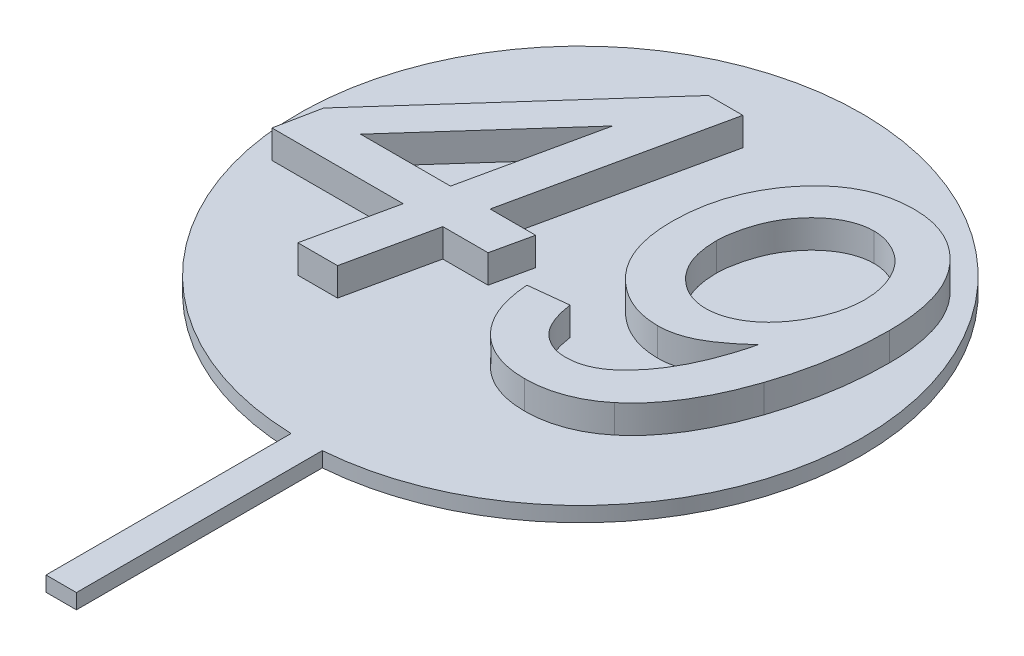
from build123d import *

# Parameters (mm, degrees)
SKETCH_1_R      = 30
EXTRUDE_1_DEPTH = 1.6
EXTRUDE_2_DEPTH = 3
SKETCH_3_W      = 3.244311069
SKETCH_3_H      = 35.273993815
EXTRUDE_5_DEPTH = 1.6


with BuildPart() as part:
    # Эскиз1 → Бобышка-Вытянуть1 (new body)
    with BuildSketch(Plane(origin=(0, 0, 0), x_dir=(1, 0, 0), z_dir=(0, 1, 0))):
        Circle(SKETCH_1_R)
    extrude(amount=EXTRUDE_1_DEPTH)

    # Эскиз2 → Бобышка-Вытянуть2 (add)
    with BuildSketch(Plane(origin=(0, 1.6, 0), x_dir=(1, 0, 0), z_dir=(0, 1, 0))):
        Polygon((-15.112940101, -15.010744766), (-13.103354207, -5.79113923), (-27.098427297, -5.79113923), (-26.176466744, -1.195742096), (-6.815295119, 20.484736546), (-3.156264172, 20.484736546), (-7.974948628, -1.642316739), (-3.127452905, -1.642316739), (-4.049413459, -5.79113923), (-8.875300731, -5.79113923), (-10.884886625, -15.010744766), align=None)
        Polygon((-12.203002104, -1.642316739), (-9.112993686, 12.561638039), (-21.797154114, -1.642316739), align=None, mode=Mode.SUBTRACT)
        with BuildLine():
            Line((1.021369586, -6.713099784), (5.155786443, -6.252119507))
            add(Edge.make_bspline(
                [(5.155786443, -6.252119507), (5.192135281, -6.473381577), (5.262387165, -6.901017726), (5.397879979, -7.515231953), (5.562416953, -8.078982569), (5.75783084, -8.594252788), (5.978056496, -9.060074627), (6.225780557, -9.477912909), (6.498384414, -9.845044122), (6.888403904, -10.266320667), (7.442457962, -10.681510063), (8.162107094, -11.060328313), (8.950693699, -11.283404951), (9.495307412, -11.309570842), (9.772792028, -11.322902552)],
                knots=[0, 0, 0, 0, 0.000672606, 0.001299954, 0.00188569, 0.002432819, 0.002951522, 0.003429575, 0.003887676, 0.004320864, 0.005147809, 0.005949945, 0.006750366, 0.007581816, 0.007581816, 0.007581816, 0.007581816], degree=3))
            add(Edge.make_bspline(
                [(9.772792028, -11.322902552), (9.974836791, -11.315289739), (10.378983376, -11.300061965), (10.979375815, -11.198014835), (11.565207937, -11.022197171), (12.140680484, -10.782461737), (12.704801504, -10.469434648), (13.257512824, -10.085992109), (13.800962323, -9.638904949), (14.138144983, -9.299567127), (14.310566627, -9.12604342)],
                knots=[0, 0, 0, 0, 0.000606108, 0.001212386, 0.001820886, 0.002437558, 0.003079094, 0.003752394, 0.004453291, 0.005186777, 0.005186777, 0.005186777, 0.005186777], degree=3))
            add(Edge.make_bspline(
                [(14.310566627, -9.12604342), (14.562332157, -8.846489735), (15.074816945, -8.277440386), (15.771928843, -7.338032377), (16.413643396, -6.306492), (17.009949904, -5.193403292), (17.552241758, -3.989577112), (18.036311249, -2.697590667), (18.489551109, -1.323270245), (18.731729262, -0.366685376), (18.855544044, 0.122373383)],
                knots=[0, 0, 0, 0, 0.001128178, 0.002296479, 0.003503568, 0.004769995, 0.006082035, 0.007461238, 0.008907642, 0.010420662, 0.010420662, 0.010420662, 0.010420662], degree=3))
            add(Edge.make_bspline(
                [(18.855544044, 0.122373383), (18.515554142, -0.181681505), (17.868313732, -0.760512257), (16.895223997, -1.523524974), (15.986257834, -2.159743633), (15.121792782, -2.661558355), (14.274538335, -3.030078632), (13.434324295, -3.290513005), (12.583841099, -3.459331039), (12.011241698, -3.477265014), (11.724755387, -3.486237846)],
                knots=[0, 0, 0, 0, 0.001368042, 0.002604349, 0.003707227, 0.004694433, 0.005597662, 0.0064725, 0.007329998, 0.008188615, 0.008188615, 0.008188615, 0.008188615], degree=3))
            add(Edge.make_bspline(
                [(11.724755387, -3.486237846), (11.467545037, -3.478838371), (10.95835582, -3.464189922), (10.202997804, -3.361403617), (9.470361257, -3.188438097), (8.755779823, -2.949020303), (8.065155466, -2.63719131), (7.391074846, -2.26158419), (6.74101139, -1.813836573), (6.334287268, -1.470552033), (6.128166715, -1.296581532)],
                knots=[0, 0, 0, 0, 0.000771542, 0.001527392, 0.002282143, 0.003026964, 0.003784631, 0.004552094, 0.00533928, 0.006148115, 0.006148115, 0.006148115, 0.006148115], degree=3))
            add(Edge.make_bspline(
                [(6.128166715, -1.296581532), (5.866741871, -1.053430833), (5.344675784, -0.567858261), (4.68598861, 0.277826316), (4.120100969, 1.190125333), (3.651772278, 2.178943205), (3.306695947, 3.251277107), (3.042972026, 4.394926248), (2.892902816, 5.618933407), (2.874665369, 6.460451788), (2.865290693, 6.893021198)],
                knots=[0, 0, 0, 0, 0.001069612, 0.002136018, 0.003203397, 0.004286026, 0.00540895, 0.006576162, 0.0078028, 0.009100287, 0.009100287, 0.009100287, 0.009100287], degree=3))
            add(Edge.make_bspline(
                [(2.865290693, 6.893021198), (2.875207181, 7.388228075), (2.89472349, 8.362828189), (3.083578082, 9.796121672), (3.373185787, 11.176809481), (3.796125522, 12.501570161), (4.330630954, 13.774732447), (4.980823191, 14.99643932), (5.751264631, 16.165307898), (6.355998775, 16.881862763), (6.66117516, 17.243468975)],
                knots=[0, 0, 0, 0, 0.001484899, 0.00292238, 0.004329457, 0.005712191, 0.007087382, 0.00846651, 0.00985891, 0.011277426, 0.011277426, 0.011277426, 0.011277426], degree=3))
            add(Edge.make_bspline(
                [(6.66117516, 17.243468975), (6.934144804, 17.537158668), (7.47161345, 18.115424437), (8.359517632, 18.87278791), (9.296948211, 19.509609385), (10.272237605, 20.044447486), (11.302446737, 20.446715103), (12.37692951, 20.736367773), (13.497965187, 20.913646613), (14.261903613, 20.934929686), (14.649099018, 20.945716823)],
                knots=[0, 0, 0, 0, 0.001202159, 0.002367012, 0.003491782, 0.004597221, 0.005696684, 0.006800948, 0.007930689, 0.009091773, 0.009091773, 0.009091773, 0.009091773], degree=3))
            add(Edge.make_bspline(
                [(14.649099018, 20.945716823), (14.997787132, 20.936379292), (15.681760043, 20.918063159), (16.687233548, 20.762950374), (17.64616698, 20.504084004), (18.560197693, 20.142451509), (19.424142306, 19.676277717), (20.242163935, 19.110195911), (21.017638488, 18.442114073), (21.740577275, 17.67553899), (22.398010202, 16.814571371), (22.978272504, 15.868653702), (23.458966364, 14.829820422), (23.856664916, 13.711476165), (24.153976582, 12.506286792), (24.379655281, 11.221838923), (24.507641015, 9.848780448), (24.523306789, 8.905267443), (24.531363702, 8.420018365)],
                knots=[0, 0, 0, 0, 0.001045625, 0.002051056, 0.003043504, 0.004019904, 0.004993138, 0.00598213, 0.006998544, 0.008058362, 0.009137391, 0.010242994, 0.011380446, 0.012565085, 0.01379843, 0.015099829, 0.016474492, 0.017930103, 0.017930103, 0.017930103, 0.017930103], degree=3))
            add(Edge.make_bspline(
                [(24.531363702, 8.420018365), (24.525664072, 7.934918015), (24.514284046, 6.966354111), (24.427262909, 5.516930729), (24.273582197, 4.073215956), (24.065445524, 2.633838437), (23.799008275, 1.199214086), (23.472015699, -0.229682915), (23.095999668, -1.657124653), (22.790400156, -2.596840611), (22.637022877, -3.068474471)],
                knots=[0, 0, 0, 0, 0.001455254, 0.002905598, 0.004354081, 0.005809709, 0.007267635, 0.008730162, 0.010206528, 0.011694097, 0.011694097, 0.011694097, 0.011694097], degree=3))
            add(Edge.make_bspline(
                [(22.637022877, -3.068474471), (22.445421429, -3.608260191), (22.072409742, -4.659120639), (21.438427503, -6.164879435), (20.744443812, -7.554296537), (20.013593824, -8.845074722), (19.218836128, -10.01903208), (18.382278177, -11.090308185), (17.500898079, -12.058312556), (16.853999376, -12.618129566), (16.536237026, -12.893116619)],
                knots=[0, 0, 0, 0, 0.00171814, 0.003344892, 0.004897513, 0.006375197, 0.00779159, 0.009146026, 0.01045087, 0.011710621, 0.011710621, 0.011710621, 0.011710621], degree=3))
            add(Edge.make_bspline(
                [(16.536237026, -12.893116619), (16.275517551, -13.099437091), (15.75979639, -13.50755326), (14.936658101, -14.031619265), (14.08857004, -14.475834427), (13.213812191, -14.833383605), (12.320192974, -15.126680855), (11.398582261, -15.328844612), (10.452772335, -15.443440865), (9.813908073, -15.462246084), (9.491882172, -15.471725043)],
                knots=[0, 0, 0, 0, 0.000996907, 0.001971952, 0.002922341, 0.00386536, 0.00480383, 0.005740556, 0.006691137, 0.007657281, 0.007657281, 0.007657281, 0.007657281], degree=3))
            add(Edge.make_bspline(
                [(9.491882172, -15.471725043), (9.198617884, -15.465062279), (8.622044237, -15.451962922), (7.778171618, -15.341349076), (6.974083778, -15.163734203), (6.214126437, -14.906579258), (5.487258858, -14.594261932), (4.811253582, -14.191925812), (4.168798029, -13.730625352), (3.581420174, -13.187339966), (3.039567521, -12.584738429), (2.563524473, -11.915474189), (2.143250657, -11.193544766), (1.789964119, -10.411188257), (1.502466787, -9.568624311), (1.27386085, -8.670395225), (1.104806925, -7.712140535), (1.049695435, -7.052260618), (1.021369586, -6.713099784)],
                knots=[0, 0, 0, 0, 0.000879481, 0.001729108, 0.002548648, 0.003345854, 0.004132776, 0.004917222, 0.005700974, 0.006501394, 0.007312503, 0.008128045, 0.008960711, 0.009814936, 0.010698742, 0.011628129, 0.012593226, 0.013613817, 0.013613817, 0.013613817, 0.013613817], degree=3))
        make_face()
        with BuildLine():
            add(Edge.make_bspline(
                [(7.014113184, 7.498057811), (7.019768123, 7.243317269), (7.030786271, 6.746977844), (7.112971363, 6.022465552), (7.237466445, 5.336389944), (7.429107785, 4.691874289), (7.662640551, 4.083140966), (7.963120255, 3.518815935), (8.307660253, 2.991004091), (8.703683128, 2.507822029), (9.141020711, 2.081613788), (9.598578365, 1.703117561), (10.071970051, 1.374977493), (10.574224084, 1.115081458), (11.093650898, 0.91285426), (11.631959273, 0.767655698), (12.189958182, 0.678560926), (12.569555519, 0.667958611), (12.76196101, 0.662584645)],
                knots=[0, 0, 0, 0, 0.000764042, 0.001488668, 0.00218511, 0.002852956, 0.003503007, 0.004137714, 0.004767003, 0.005391367, 0.00600766, 0.006596047, 0.007171417, 0.007731988, 0.008288426, 0.008840559, 0.00940187, 0.009978815, 0.009978815, 0.009978815, 0.009978815], degree=3))
            add(Edge.make_bspline(
                [(12.76196101, 0.662584645), (13.05139438, 0.676731012), (13.638138298, 0.705408752), (14.512398022, 0.935715715), (15.382277568, 1.299423228), (16.240003107, 1.808003519), (17.070741272, 2.454050946), (17.83396819, 3.259410645), (18.547032162, 4.195807232), (19.170277098, 5.263560877), (19.709790373, 6.398811887), (20.094032745, 7.57986936), (20.33518312, 8.775140421), (20.366777551, 9.580970443), (20.382541211, 9.983029616)],
                knots=[0, 0, 0, 0, 0.000867334, 0.001758273, 0.002694639, 0.003689072, 0.004740905, 0.005841216, 0.007008095, 0.008264383, 0.009543689, 0.010771405, 0.011982014, 0.013187491, 0.013187491, 0.013187491, 0.013187491], degree=3))
            add(Edge.make_bspline(
                [(20.382541211, 9.983029616), (20.372951463, 10.295722068), (20.354025111, 10.912852788), (20.200419667, 11.820980608), (19.936709411, 12.688869248), (19.587274972, 13.514264205), (19.151964964, 14.277348135), (18.633780293, 14.952051568), (18.035571041, 15.522736313), (17.372002119, 15.97945588), (16.675354278, 16.338724835), (15.964465751, 16.60024492), (15.24524014, 16.769356322), (14.760441115, 16.787750578), (14.519448315, 16.796894332)],
                knots=[0, 0, 0, 0, 0.000937723, 0.001850692, 0.002753088, 0.003653468, 0.004534364, 0.005381515, 0.006196675, 0.007003905, 0.007789937, 0.008541933, 0.009272406, 0.009994451, 0.009994451, 0.009994451, 0.009994451], degree=3))
            add(Edge.make_bspline(
                [(14.519448315, 16.796894332), (14.288282748, 16.789085648), (13.824283604, 16.773411934), (13.13177034, 16.628464349), (12.446585191, 16.395690831), (11.768928129, 16.078840648), (11.110004943, 15.671818458), (10.476966926, 15.17730675), (9.858820739, 14.606825776), (9.28343841, 13.947489545), (8.752685138, 13.222672572), (8.278203551, 12.443585563), (7.892711178, 11.60155963), (7.576689262, 10.730159546), (7.323697649, 9.861582737), (7.155792922, 9.02703603), (7.036547924, 8.245734242), (7.02140133, 7.740947846), (7.014113184, 7.498057811)],
                knots=[0, 0, 0, 0, 0.00069282, 0.001390638, 0.002112683, 0.00286025, 0.003629874, 0.00443091, 0.005266747, 0.006149643, 0.007051492, 0.007959419, 0.008881042, 0.009824418, 0.010738609, 0.011591831, 0.012377202, 0.013105578, 0.013105578, 0.013105578, 0.013105578], degree=3))
        make_face(mode=Mode.SUBTRACT)
    extrude(amount=EXTRUDE_2_DEPTH)

    # Эскиз3 → Бобышка-Вытянуть5 (add)
    with BuildSketch(Plane.XZ):
        with Locations((0.764892295, 38.487099642)):
            Rectangle(SKETCH_3_W, SKETCH_3_H)
    extrude(amount=-EXTRUDE_5_DEPTH)


solid = part.part
